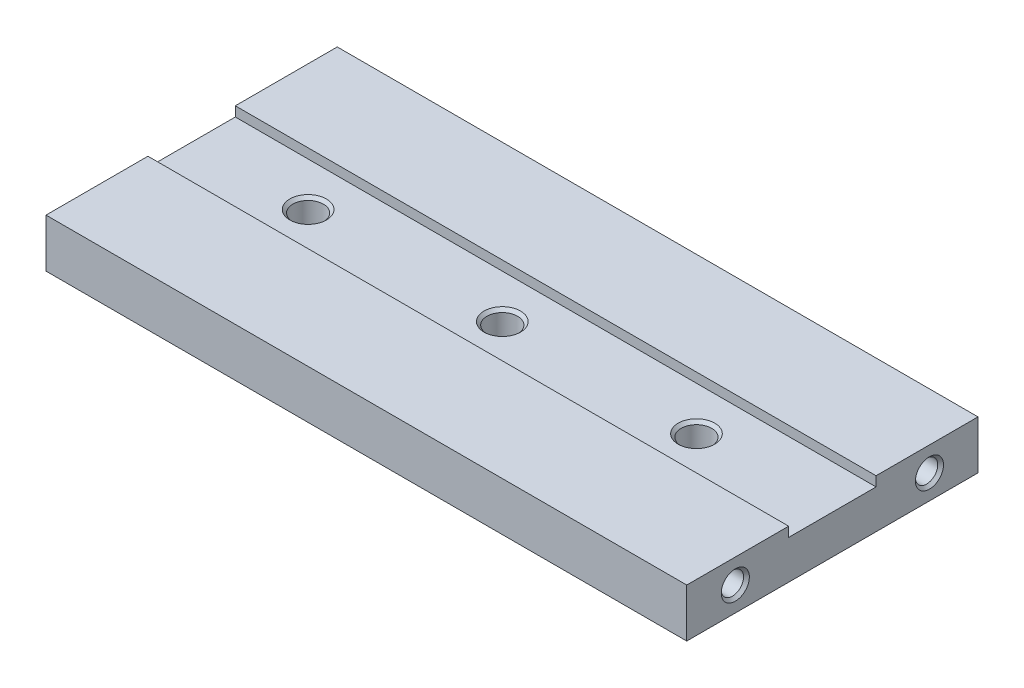
from build123d import *

# Parameters (mm, degrees)
ESBO_O1_W                                            = 66
ESBO_O1_H                                            = 30
RESSALTO_EXTRUS_O1_DEPTH                             = 5
ESBO_O2_W                                            = 66
ESBO_O2_H                                            = 9
CORTE_EXTRUS_O1_DEPTH                                = 1
FURO_ROSCADO_PARA_CONDU_TE_DE_M2_2X0_451_D           = 2.3
FURO_ROSCADO_PARA_CONDU_TE_DE_M2_2X0_451_DEPTH       = 6
FURO_ROSCADO_PARA_CONDU_TE_DE_M2_2X0_451_CSINK_D     = 2.895
FURO_ROSCADO_PARA_CONDU_TE_DE_M2_2X0_451_CSINK_ANGLE = 90
FURO_ROSCADO_PARA_CONDU_TE_DE_M2_2X0_451_TIP         = 0.690989712
FURO_ROSCADO_PARA_CONDU_TE_DE_M2_2X0_452_D           = 2.3
FURO_ROSCADO_PARA_CONDU_TE_DE_M2_2X0_452_DEPTH       = 6
FURO_ROSCADO_PARA_CONDU_TE_DE_M2_2X0_452_CSINK_D     = 2.895
FURO_ROSCADO_PARA_CONDU_TE_DE_M2_2X0_452_CSINK_ANGLE = 90
FURO_ROSCADO_PARA_CONDU_TE_DE_M2_2X0_452_TIP         = 0.690989712
FURO_ROSCADO_PARA_CONDU_TE_DE_M3X0_53_D              = 3.15
FURO_ROSCADO_PARA_CONDU_TE_DE_M3X0_53_CSINK_D        = 3.766
FURO_ROSCADO_PARA_CONDU_TE_DE_M3X0_53_CSINK_ANGLE    = 90


with BuildPart() as part:
    # Esboço1 → Ressalto-extrusão1 (new body)
    with BuildSketch(Plane(origin=(0, 0, 0), x_dir=(1, 0, 0), z_dir=(0, 1, 0))):
        Rectangle(ESBO_O1_W, ESBO_O1_H)
    extrude(amount=RESSALTO_EXTRUS_O1_DEPTH)

    # Esboço2 → Corte-extrusão1 (cut)
    with BuildSketch(Plane(origin=(0, 5, 0), x_dir=(1, 0, 0), z_dir=(0, 1, 0))):
        Rectangle(ESBO_O2_W, ESBO_O2_H)
    extrude(amount=-CORTE_EXTRUS_O1_DEPTH, mode=Mode.SUBTRACT)

    # Furo roscado para conduíte de M2.2x0.451
    with Locations(Plane(origin=(33, 0, 0), x_dir=(0, 0, -1), z_dir=(1, 0, 0))):
        with Locations((-10, 2.5), (10, 2.5)):
            CounterSinkHole(FURO_ROSCADO_PARA_CONDU_TE_DE_M2_2X0_451_D / 2, FURO_ROSCADO_PARA_CONDU_TE_DE_M2_2X0_451_CSINK_D / 2, depth=FURO_ROSCADO_PARA_CONDU_TE_DE_M2_2X0_451_DEPTH, counter_sink_angle=FURO_ROSCADO_PARA_CONDU_TE_DE_M2_2X0_451_CSINK_ANGLE)
            with Locations((0, 0, -(FURO_ROSCADO_PARA_CONDU_TE_DE_M2_2X0_451_DEPTH + FURO_ROSCADO_PARA_CONDU_TE_DE_M2_2X0_451_TIP / 2))):  # 118° drill point
                Cone(0, FURO_ROSCADO_PARA_CONDU_TE_DE_M2_2X0_451_D / 2, FURO_ROSCADO_PARA_CONDU_TE_DE_M2_2X0_451_TIP, mode=Mode.SUBTRACT)

    # Furo roscado para conduíte de M2.2x0.452
    with Locations(Plane.ZY.offset(33)):
        with Locations((-10, 2.5), (10, 2.5)):
            CounterSinkHole(FURO_ROSCADO_PARA_CONDU_TE_DE_M2_2X0_452_D / 2, FURO_ROSCADO_PARA_CONDU_TE_DE_M2_2X0_452_CSINK_D / 2, depth=FURO_ROSCADO_PARA_CONDU_TE_DE_M2_2X0_452_DEPTH, counter_sink_angle=FURO_ROSCADO_PARA_CONDU_TE_DE_M2_2X0_452_CSINK_ANGLE)
            with Locations((0, 0, -(FURO_ROSCADO_PARA_CONDU_TE_DE_M2_2X0_452_DEPTH + FURO_ROSCADO_PARA_CONDU_TE_DE_M2_2X0_452_TIP / 2))):  # 118° drill point
                Cone(0, FURO_ROSCADO_PARA_CONDU_TE_DE_M2_2X0_452_D / 2, FURO_ROSCADO_PARA_CONDU_TE_DE_M2_2X0_452_TIP, mode=Mode.SUBTRACT)

    # Furo roscado para conduíte de M3x0.53 (through all)
    with Locations(Plane(origin=(0, 4, 0), x_dir=(1, 0, 0), z_dir=(0, 1, 0))):
        with Locations((-21, 0), (-1, 0), (19, 0)):
            CounterSinkHole(FURO_ROSCADO_PARA_CONDU_TE_DE_M3X0_53_D / 2, FURO_ROSCADO_PARA_CONDU_TE_DE_M3X0_53_CSINK_D / 2, counter_sink_angle=FURO_ROSCADO_PARA_CONDU_TE_DE_M3X0_53_CSINK_ANGLE)


solid = part.part
